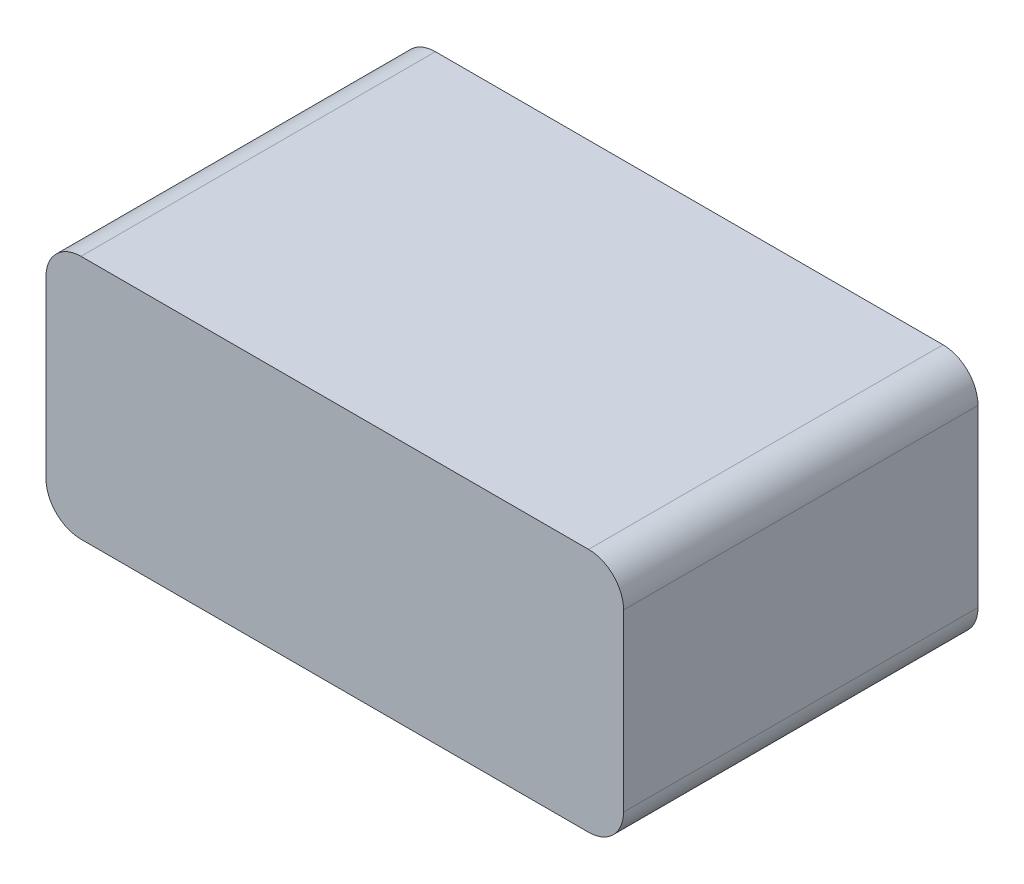
from build123d import *

# Parameters (mm, degrees)
SKETCH1_W           = 209.55
SKETCH1_H           = 128.5875
BOSS_EXTRUDE1_DEPTH = 88.9
FILLET1_R           = 12.7
FILLET2_R           = 12.7
FILLET3_R           = 12.7
FILLET4_R           = 12.7
SHELL1_T            = -2.54


with BuildPart() as part:
    # Sketch1 → Boss-Extrude1 (new body)
    with BuildSketch(Plane(origin=(0, 0, 0), x_dir=(1, 0, 0), z_dir=(0, 1, 0))):
        with Locations((79.577166722, 28.014941846)):
            Rectangle(SKETCH1_W, SKETCH1_H)
    extrude(amount=BOSS_EXTRUDE1_DEPTH)

    # Fillet1
    fillet1_edges = [part.edges().sort_by_distance(p)[0] for p in [
        (184.352166722, 88.9, -28.014941846),
    ]]
    fillet(fillet1_edges, radius=FILLET1_R)

    # Fillet2
    fillet2_edges = [part.edges().sort_by_distance(p)[0] for p in [
        (-25.197833278, 88.9, -28.014941846),
    ]]
    fillet(fillet2_edges, radius=FILLET2_R)

    # Fillet3
    fillet3_edges = [part.edges().sort_by_distance(p)[0] for p in [
        (-25.197833278, 0, -28.014941846),
    ]]
    fillet(fillet3_edges, radius=FILLET3_R)

    # Fillet4
    fillet4_edges = [part.edges().sort_by_distance(p)[0] for p in [
        (184.352166722, 0, -28.014941846),
    ]]
    fillet(fillet4_edges, radius=FILLET4_R)

    # Shell1
    shell1_openings = [part.faces().sort_by_distance(p)[0] for p in [
        (79.577166722, 44.45, -92.308691846),
    ]]
    offset(amount=SHELL1_T, openings=shell1_openings, kind=Kind.INTERSECTION)


solid = part.part
